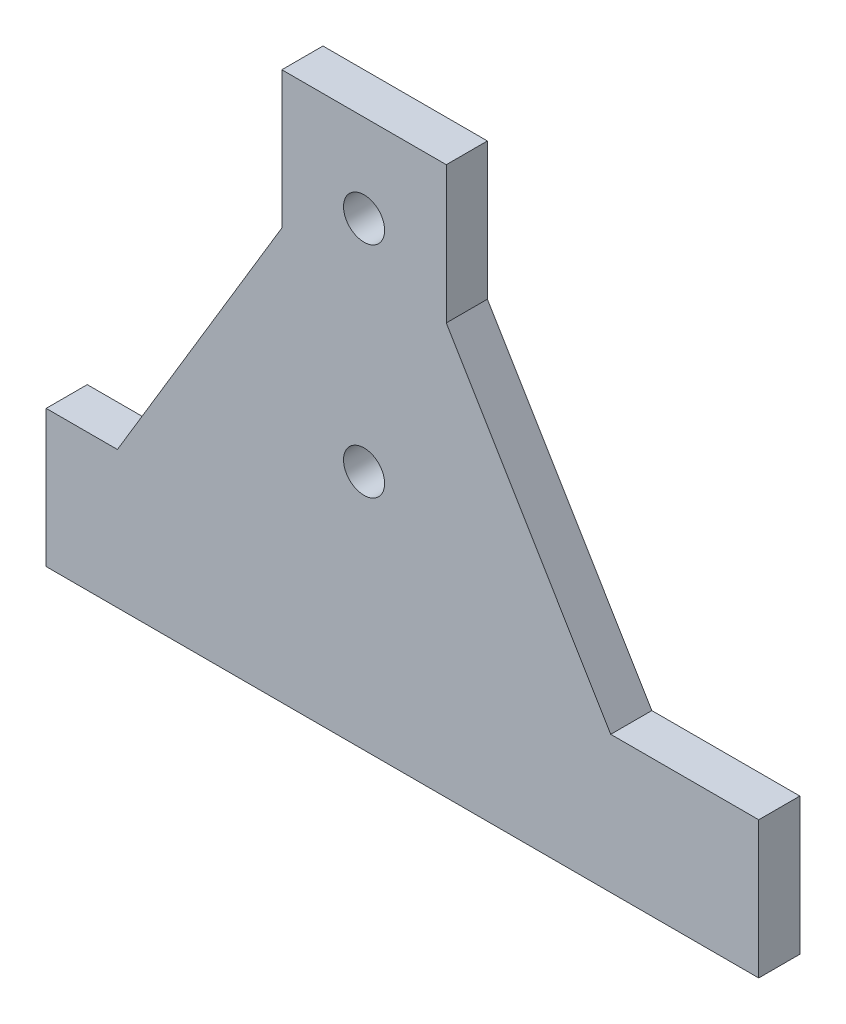
from build123d import *

# Parameters (mm, degrees)
ESQUISSE1_R        = 7.5
BOSS_EXTRU_1_DEPTH = 15


with BuildPart() as part:
    # Esquisse1 → Boss.-Extru.1 (new body)
    with BuildSketch(Plane.XY):
        Polygon((-130, 0), (-130, 50), (-104, 50), (-44, 150), (-44, 200), (16, 200), (16, 150), (76, 50), (130, 50), (130, 0), align=None)
        with Locations((-14, 168)):
            Circle(ESQUISSE1_R, mode=Mode.SUBTRACT)
        with Locations((-14, 88)):
            Circle(ESQUISSE1_R, mode=Mode.SUBTRACT)
    extrude(amount=BOSS_EXTRU_1_DEPTH)


solid = part.part
